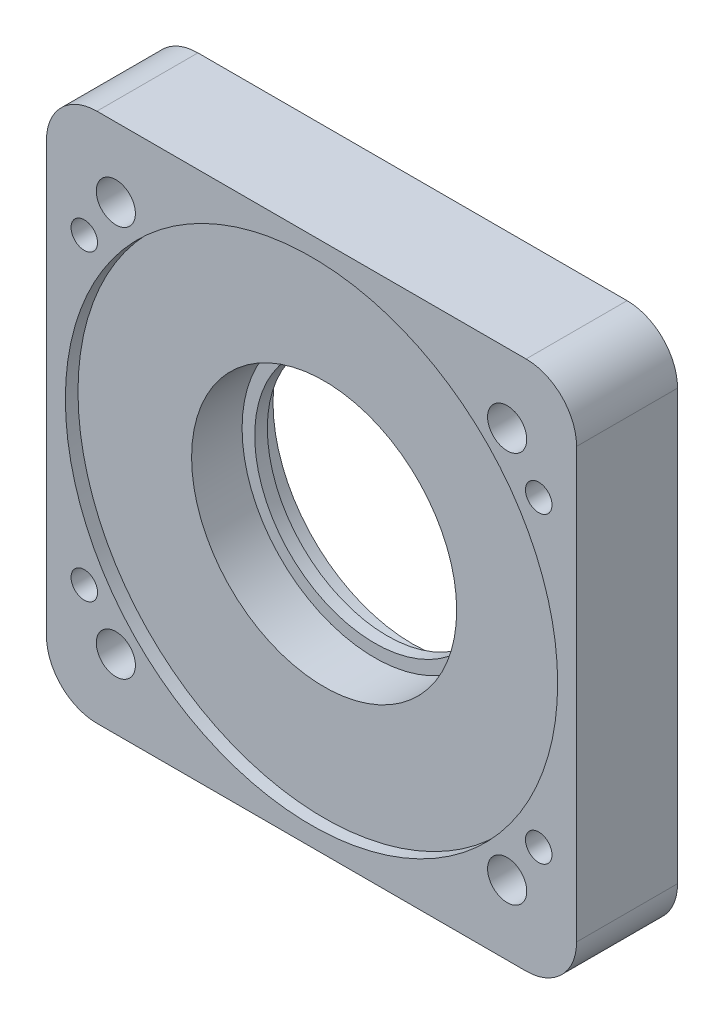
from build123d import *

# Parameters (mm, degrees)
SKETCH_1_W          = 42
SKETCH_1_H          = 42
EXTRUDE_1_DEPTH     = 8
SKETCH_2_R          = 9.5
CUT_EXTRUDE_1_DEPTH = 9
SKETCH_3_R          = 10.5
CUT_EXTRUDE_2_DEPTH = 5
SKETCH_6_R          = 11.05
CUT_EXTRUDE_3_DEPTH = 2
FILLET_1_R          = 4
SKETCH_8_R          = 19.5
CUT_EXTRUDE_4_DEPTH = 1
SKETCH_9_R          = 1.55
CUT_EXTRUDE_5_DEPTH = 9
SKETCH_10_R         = 1.55
CUT_EXTRUDE_6_DEPTH = 9
SKETCH_11_R         = 1.55
SKETCH_11_R_2       = 1.05
EXTRUDE_3_DEPTH     = 2


with BuildPart() as part:
    # 草图1 → 凸台-拉伸1 (new body)
    with BuildSketch(Plane.XY):
        Rectangle(SKETCH_1_W, SKETCH_1_H)
    extrude(amount=EXTRUDE_1_DEPTH)

    # 草图2 → 切除-拉伸1 (cut, through all)
    with BuildSketch(Plane.XY.offset(8)):
        Circle(SKETCH_2_R)
    extrude(amount=-CUT_EXTRUDE_1_DEPTH, mode=Mode.SUBTRACT)

    # 草图3 → 切除-拉伸2 (cut)
    with BuildSketch(Plane.XY.offset(8)):
        Circle(SKETCH_3_R)
    extrude(amount=-CUT_EXTRUDE_2_DEPTH, mode=Mode.SUBTRACT)

    # 草图6 → 切除-拉伸3 (cut)
    with BuildSketch(Plane(origin=(0, 0, 0), x_dir=(-1, 0, 0), z_dir=(0, 0, -1))):
        Circle(SKETCH_6_R)
    extrude(amount=-CUT_EXTRUDE_3_DEPTH, mode=Mode.SUBTRACT)

    # 圆角1
    fillet_1_edges = [part.edges().sort_by_distance(p)[0] for p in [
        (21, -21, 4),
        (-21, -21, 4),
        (-21, 21, 4),
        (21, 21, 4),
    ]]
    fillet(fillet_1_edges, radius=FILLET_1_R)

    # 草图8 → 切除-拉伸4 (cut)
    with BuildSketch(Plane.XY.offset(8)):
        Circle(SKETCH_8_R)
    extrude(amount=-CUT_EXTRUDE_4_DEPTH, mode=Mode.SUBTRACT)

    # 草图9 → 切除-拉伸5 (cut, through all)
    with BuildSketch(Plane(origin=(0, 0, 0), x_dir=(-1, 0, 0), z_dir=(0, 0, -1))):
        with Locations((-15.5, 15.5)):
            Circle(SKETCH_9_R)
        with Locations((15.5, 15.5)):
            Circle(SKETCH_9_R)
        with Locations((15.5, -15.5)):
            Circle(SKETCH_9_R)
        with Locations((-15.5, -15.5)):
            Circle(SKETCH_9_R)
    extrude(amount=-CUT_EXTRUDE_5_DEPTH, mode=Mode.SUBTRACT)

    # 草图10 → 切除-拉伸6 (cut, through all)
    with BuildSketch(Plane(origin=(0, 0, 0), x_dir=(-1, 0, 0), z_dir=(0, 0, -1))):
        with Locations((-18, 12)):
            Circle(SKETCH_10_R)
        with Locations((18, 12)):
            Circle(SKETCH_10_R)
        with Locations((18, -12)):
            Circle(SKETCH_10_R)
        with Locations((-18, -12)):
            Circle(SKETCH_10_R)
    extrude(amount=-CUT_EXTRUDE_6_DEPTH, mode=Mode.SUBTRACT)

    # 草图11 → 凸台-拉伸3 (add)
    with BuildSketch(Plane.XY.offset(8)):
        with Locations((-18, 12)):
            Circle(SKETCH_11_R)
        with Locations((-18, 12)):
            Circle(SKETCH_11_R_2, mode=Mode.SUBTRACT)
        with Locations((18, 12)):
            Circle(SKETCH_11_R)
        with Locations((18, 12)):
            Circle(SKETCH_11_R_2, mode=Mode.SUBTRACT)
        with Locations((18, -12)):
            Circle(SKETCH_11_R)
        with Locations((18, -12)):
            Circle(SKETCH_11_R_2, mode=Mode.SUBTRACT)
        with Locations((-18, -12)):
            Circle(SKETCH_11_R)
        with Locations((-18, -12)):
            Circle(SKETCH_11_R_2, mode=Mode.SUBTRACT)
    extrude(amount=-EXTRUDE_3_DEPTH)


solid = part.part
